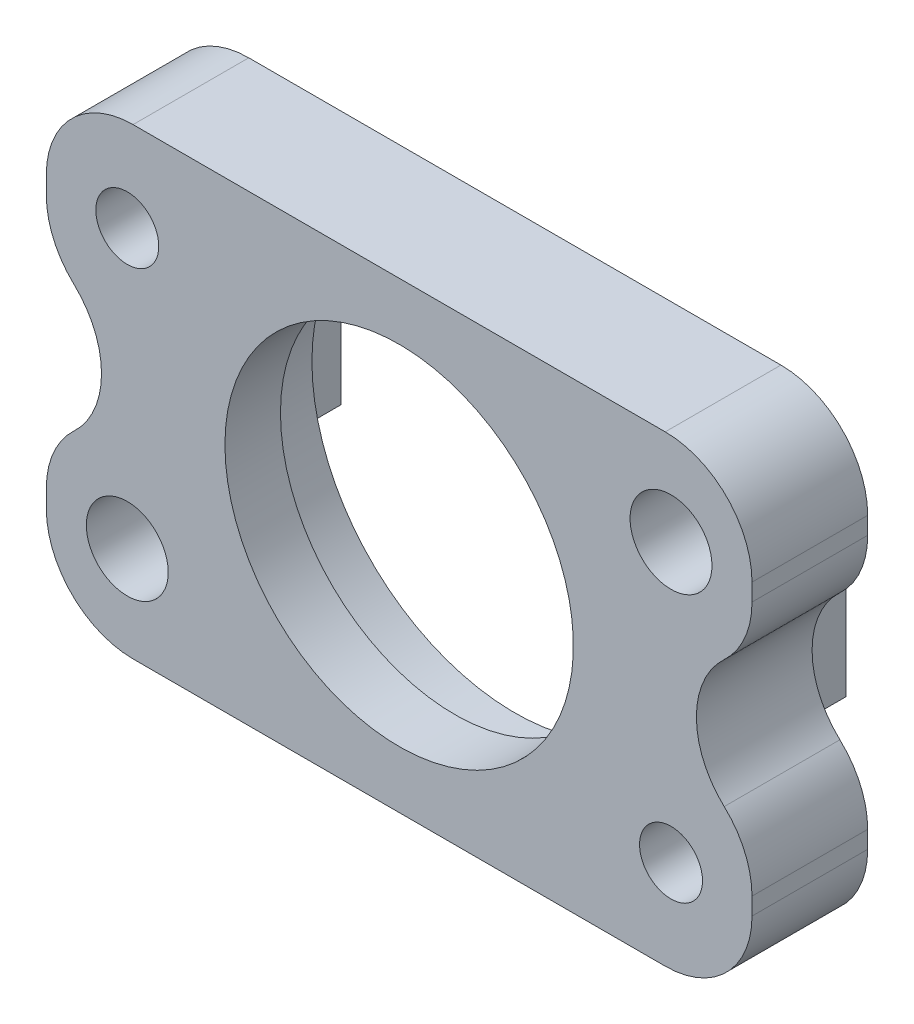
from build123d import *

# Parameters (mm, degrees)
SKETCH1_W                       = 38.735
SKETCH1_H                       = 25.4
BOSS_EXTRUDE1_DEPTH             = 6.35
CUT_EXTRUDE1_DEPTH              = 7.35
CUT_EXTRUDE2_DEPTH              = 7.35
SKETCH4_W                       = 2.286
SKETCH4_H                       = 8.89
BOSS_EXTRUDE2_DEPTH             = 3.175
SKETCH5_W                       = 2.286
SKETCH5_H                       = 8.89
BOSS_EXTRUDE3_DEPTH             = 3.175
HOLE1_D                         = 19.1262
HOLE1_DEPTH                     = 6.35
HOLE1_CBORE_D                   = 22.2758
HOLE1_CBORE_DEPTH               = 3.302
F_16_0_177_DIAMETER_HOLE1_D     = 4.4958
F_16_0_177_DIAMETER_HOLE1_DEPTH = 9.525
F_29_0_136_DIAMETER_HOLE1_D     = 3.4544
F_29_0_136_DIAMETER_HOLE1_DEPTH = 9.525
FILLET1_R                       = 4.7625


with BuildPart() as part:
    # Sketch1 → Boss-Extrude1 (new body)
    with BuildSketch(Plane.XY.offset(6.35)):
        with Locations((-234.6325, 25.4)):
            Rectangle(SKETCH1_W, SKETCH1_H)
    extrude(amount=-BOSS_EXTRUDE1_DEPTH)

    # Sketch2 → Cut-Extrude1 (cut, through all)
    with BuildSketch(Plane(origin=(0, 0, 0), x_dir=(-1, 0, 0), z_dir=(0, 0, -1))):
        with BuildLine():
            Line((215.265, 32.388210744), (215.265, 18.411789256))
            ThreePointArc((215.265, 18.411789256), (215.6632391, 20.318260617), (216.791355087, 21.905894628))
            ThreePointArc((216.791355087, 21.905894628), (218.317710174, 25.4), (216.791355087, 28.894105372))
            ThreePointArc((216.791355087, 28.894105372), (215.6632391, 30.481739383), (215.265, 32.388210744))
        make_face()
    extrude(amount=-CUT_EXTRUDE1_DEPTH, mode=Mode.SUBTRACT)

    # Sketch3 → Cut-Extrude2 (cut, through all)
    with BuildSketch(Plane(origin=(0, 0, 0), x_dir=(-1, 0, 0), z_dir=(0, 0, -1))):
        with BuildLine():
            Line((254, 20.955), (254, 29.845))
            ThreePointArc((254, 29.845), (250.969652441, 25.4), (254, 20.955))
        make_face()
    extrude(amount=-CUT_EXTRUDE2_DEPTH, mode=Mode.SUBTRACT)

    # Sketch4 → Boss-Extrude2 (add)
    with BuildSketch(Plane(origin=(0, 0, 0), x_dir=(-1, 0, 0), z_dir=(0, 0, -1))):
        with Locations((220.7641, 25.4)):
            Rectangle(SKETCH4_W, SKETCH4_H)
    extrude(amount=BOSS_EXTRUDE2_DEPTH)

    # Sketch5 → Boss-Extrude3 (add)
    with BuildSketch(Plane(origin=(0, 0, 0), x_dir=(-1, 0, 0), z_dir=(0, 0, -1))):
        with Locations((248.5009, 25.4)):
            Rectangle(SKETCH5_W, SKETCH5_H)
    extrude(amount=BOSS_EXTRUDE3_DEPTH)

    # Hole1
    with Locations(Plane(origin=(0, 0, 0), x_dir=(-1, 0, 0), z_dir=(0, 0, -1))):
        with Locations((234.6325, 25.4)):
            CounterBoreHole(HOLE1_D / 2, HOLE1_CBORE_D / 2, HOLE1_CBORE_DEPTH, depth=HOLE1_DEPTH)

    # #16 (0.177) Diameter Hole1
    with Locations(Plane.XY.offset(6.35)):
        with Locations((-249.555, 17.78), (-219.71, 33.02)):
            Hole(F_16_0_177_DIAMETER_HOLE1_D / 2, depth=F_16_0_177_DIAMETER_HOLE1_DEPTH)

    # #29 (0.136) Diameter Hole1
    with Locations(Plane.XY.offset(6.35)):
        with Locations((-219.71, 17.78), (-249.555, 33.02)):
            Hole(F_29_0_136_DIAMETER_HOLE1_D / 2, depth=F_29_0_136_DIAMETER_HOLE1_DEPTH)

    # Fillet1
    fillet1_edges = [part.edges().sort_by_distance(p)[0] for p in [
        (-254, 20.955, 3.175),
        (-254, 29.845, 3.175),
        (-254, 38.1, 3.175),
        (-215.265, 38.1, 3.175),
        (-215.265, 12.7, 3.175),
        (-254, 12.7, 3.175),
    ]]
    fillet(fillet1_edges, radius=FILLET1_R)


solid = part.part
